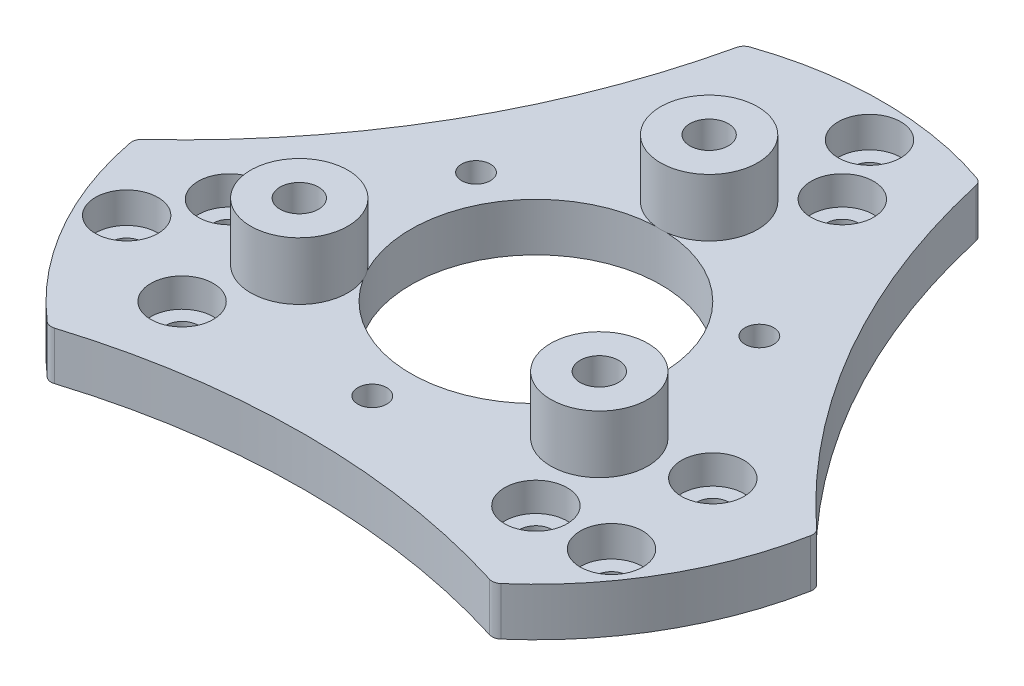
from build123d import *

# Parameters (mm, degrees)
SKETCH1_R           = 36
SKETCH1_R_2         = 13
BOSS_EXTRUDE1_DEPTH = 5
SKETCH2_R           = 1.65
CUT_EXTRUDE1_DEPTH  = 6
CIRPATTERN1_COUNT   = 3
SKETCH3_R           = 76.029468034
CUT_EXTRUDE2_DEPTH  = 10
CIRPATTERN2_COUNT   = 3
FILLET1_R           = 1
SKETCH4_R           = 5.05
BOSS_EXTRUDE2_DEPTH = 6
SKETCH7_R           = 3.25
CUT_EXTRUDE5_DEPTH  = 3.2
CIRPATTERN3_COUNT   = 3
SKETCH8_R           = 1.5
CUT_EXTRUDE6_DEPTH  = 10
SKETCH12_R          = 2
CUT_EXTRUDE8_DEPTH  = 12.0000001
CIRPATTERN4_COUNT   = 3
SKETCH13_R          = 1.7
CUT_EXTRUDE9_DEPTH  = 6.0000001
CIRPATTERN5_COUNT   = 3
SKETCH14_R          = 3.25
CUT_EXTRUDE10_DEPTH = 3


with BuildPart() as part:
    # Sketch1 → Boss-Extrude1 (new body)
    with BuildSketch(Plane(origin=(0, 0, 0), x_dir=(1, 0, 0), z_dir=(0, 1, 0))):
        Circle(SKETCH1_R)
        Circle(SKETCH1_R_2, mode=Mode.SUBTRACT)
    extrude(amount=BOSS_EXTRUDE1_DEPTH)

    # Sketch2 → Cut-Extrude1 (cut, through all)
    with BuildSketch(Plane(origin=(0, 5, 0), x_dir=(1, 0, 0), z_dir=(0, 1, 0))):
        with Locations((2.788983768, 31.878230339)):
            Circle(SKETCH2_R)
    cut_extrude1 = extrude(amount=-CUT_EXTRUDE1_DEPTH, mode=Mode.SUBTRACT)

    # CirPattern1: Cut-Extrude1 ×3 about axis
    cirpattern1_axis = Axis((0, 0, 0), (0, 1, 0))
    for i in range(1, CIRPATTERN1_COUNT):
        add(cut_extrude1.rotate(cirpattern1_axis, i * 360 / CIRPATTERN1_COUNT), mode=Mode.SUBTRACT)

    # Sketch3 → Cut-Extrude2 (cut)
    with BuildSketch(Plane(origin=(0, 5, 0), x_dir=(1, 0, 0), z_dir=(0, 1, 0))):
        with Locations((86.602540378, 50)):
            Circle(SKETCH3_R)
    cut_extrude2 = extrude(amount=-CUT_EXTRUDE2_DEPTH, mode=Mode.SUBTRACT)

    # CirPattern2: Cut-Extrude2 ×3 about axis
    cirpattern2_axis = Axis((0, 0, 0), (0, 1, 0))
    for i in range(1, CIRPATTERN2_COUNT):
        add(cut_extrude2.rotate(cirpattern2_axis, i * 360 / CIRPATTERN2_COUNT), mode=Mode.SUBTRACT)

    # Fillet1
    fillet1_edges = [part.edges().sort_by_distance(p)[0] for p in [
        (12.31272516, 2.5, -33.828934348),
        (35.453079108, 2.5, 6.251334396),
        (23.140353949, 2.5, 27.577599952),
        (-23.140353949, 2.5, 27.577599952),
        (-35.453079108, 2.5, 6.251334396),
        (-12.31272516, 2.5, -33.828934348),
    ]]
    fillet(fillet1_edges, radius=FILLET1_R)

    # Sketch4 → Boss-Extrude2 (add)
    with BuildSketch(Plane(origin=(0, 5, 0), x_dir=(1, 0, 0), z_dir=(0, 1, 0))):
        with Locations((0, 18)):
            Circle(SKETCH4_R)
    boss_extrude2 = extrude(amount=BOSS_EXTRUDE2_DEPTH)

    # Sketch7 → Cut-Extrude5 (cut)
    with BuildSketch(Plane(origin=(0, 5, 0), x_dir=(1, 0, 0), z_dir=(0, 1, 0))):
        with Locations((2.788983768, 31.878230339)):
            Circle(SKETCH7_R)
    cut_extrude5 = extrude(amount=-CUT_EXTRUDE5_DEPTH, mode=Mode.SUBTRACT)

    # CirPattern3: Boss-Extrude2, Cut-Extrude5 ×3 about axis
    cirpattern3_axis = Axis((0, 0, 0), (0, 1, 0))
    for i in range(1, CIRPATTERN3_COUNT):
        add(boss_extrude2.rotate(cirpattern3_axis, i * 360 / CIRPATTERN3_COUNT))
        add(cut_extrude5.rotate(cirpattern3_axis, i * 360 / CIRPATTERN3_COUNT), mode=Mode.SUBTRACT)

    # Sketch8 → Cut-Extrude6 (cut)
    with BuildSketch(Plane(origin=(0, 5, 0), x_dir=(1, 0, 0), z_dir=(0, 1, 0))):
        with Locations((14.722431864, 8.5)):
            Circle(SKETCH8_R)
    cut_extrude6 = extrude(amount=-CUT_EXTRUDE6_DEPTH, mode=Mode.SUBTRACT)

    # Sketch12 → Cut-Extrude8 (cut, through all)
    with BuildSketch(Plane(origin=(0, 11, 0), x_dir=(1, 0, 0), z_dir=(0, 1, 0))):
        with Locations((0, 18)):
            Circle(SKETCH12_R)
    cut_extrude8 = extrude(amount=-CUT_EXTRUDE8_DEPTH, mode=Mode.SUBTRACT)

    # CirPattern4: Cut-Extrude6, Cut-Extrude8 ×3 about axis
    cirpattern4_axis = Axis((0, 0, 0), (0, 1, 0))
    for i in range(1, CIRPATTERN4_COUNT):
        add(cut_extrude6.rotate(cirpattern4_axis, i * 360 / CIRPATTERN4_COUNT), mode=Mode.SUBTRACT)
        add(cut_extrude8.rotate(cirpattern4_axis, i * 360 / CIRPATTERN4_COUNT), mode=Mode.SUBTRACT)

    # Sketch13 → Cut-Extrude9 (cut, through all)
    with BuildSketch(Plane(origin=(0, 5, 0), x_dir=(1, 0, 0), z_dir=(0, 1, 0))):
        with Locations((6.729295173, 25.114071484)):
            Circle(SKETCH13_R)
        with Locations((-6.729295173, 25.114071484)):
            Circle(SKETCH13_R)
    cut_extrude9 = extrude(amount=-CUT_EXTRUDE9_DEPTH, mode=Mode.SUBTRACT)

    # CirPattern5: Cut-Extrude9 ×3 about axis
    cirpattern5_axis = Axis((0, 0, 0), (0, 1, 0))
    for i in range(1, CIRPATTERN5_COUNT):
        add(cut_extrude9.rotate(cirpattern5_axis, i * 360 / CIRPATTERN5_COUNT), mode=Mode.SUBTRACT)

    # Sketch14 → Cut-Extrude10 (cut)
    with BuildSketch(Plane(origin=(0, 5, 0), x_dir=(1, 0, 0), z_dir=(0, 1, 0))):
        with Locations((-18.384776311, -18.384776311)):
            Circle(SKETCH14_R)
        with Locations((-25.114071484, -6.729295173)):
            Circle(SKETCH14_R)
        with Locations((-6.729295173, 25.114071484)):
            Circle(SKETCH14_R)
        with Locations((6.729295173, 25.114071484)):
            Circle(SKETCH14_R)
        with Locations((25.114071484, -6.729295173)):
            Circle(SKETCH14_R)
        with Locations((18.384776311, -18.384776311)):
            Circle(SKETCH14_R)
    extrude(amount=-CUT_EXTRUDE10_DEPTH, mode=Mode.SUBTRACT)


solid = part.part
